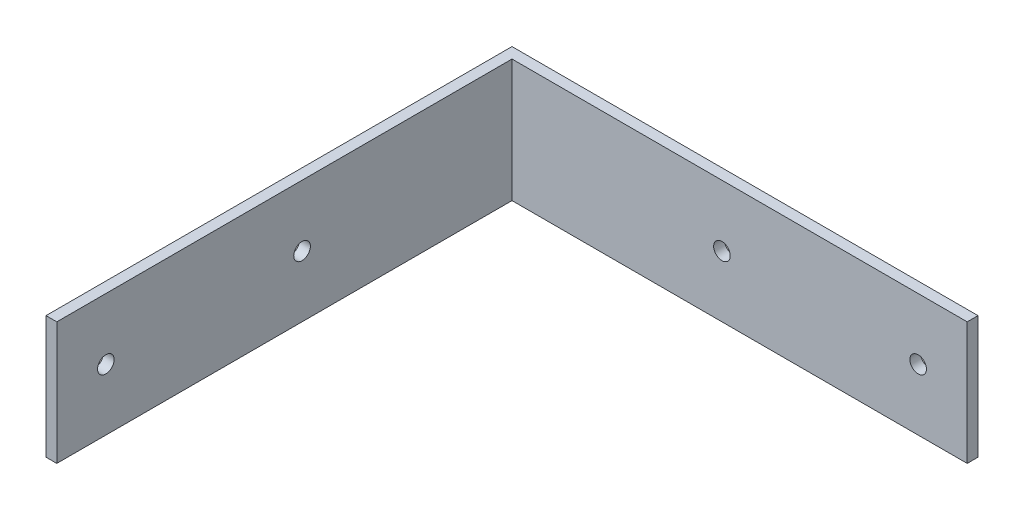
from build123d import *

# Parameters (mm, degrees)
BOSS_EXTRUDE1_DEPTH       = 31.75
F_8_CLEARANCE_HOLE1_D     = 4.3053
F_8_CLEARANCE_HOLE1_DEPTH = 6.35
F_8_CLEARANCE_HOLE1_TIP   = 1.293442612
F_8_CLEARANCE_HOLE2_D     = 4.3053
F_8_CLEARANCE_HOLE2_DEPTH = 6.35
F_8_CLEARANCE_HOLE2_TIP   = 1.293442612


with BuildPart() as part:
    # Sketch1 → Boss-Extrude1 (new body)
    with BuildSketch(Plane(origin=(0, 0, 0), x_dir=(1, 0, 0), z_dir=(0, 1, 0))):
        Polygon((0, 0), (120.65, 0), (120.65, -2.794), (2.794, -2.794), (2.794, -120.65), (0, -120.65), align=None)
    extrude(amount=BOSS_EXTRUDE1_DEPTH)

    # #8 Clearance Hole1
    with Locations(Plane(origin=(0, 0, 0), x_dir=(-1, 0, 0), z_dir=(0, 0, -1))):
        with Locations((-107.95, 15.875), (-57.15, 15.875)):
            Hole(F_8_CLEARANCE_HOLE1_D / 2, depth=F_8_CLEARANCE_HOLE1_DEPTH)
            with Locations((0, 0, -(F_8_CLEARANCE_HOLE1_DEPTH + F_8_CLEARANCE_HOLE1_TIP / 2))):  # 118° drill point
                Cone(0, F_8_CLEARANCE_HOLE1_D / 2, F_8_CLEARANCE_HOLE1_TIP, mode=Mode.SUBTRACT)

    # #8 Clearance Hole2
    with Locations(Plane.ZY):
        with Locations((107.95, 15.875), (57.15, 15.875)):
            Hole(F_8_CLEARANCE_HOLE2_D / 2, depth=F_8_CLEARANCE_HOLE2_DEPTH)
            with Locations((0, 0, -(F_8_CLEARANCE_HOLE2_DEPTH + F_8_CLEARANCE_HOLE2_TIP / 2))):  # 118° drill point
                Cone(0, F_8_CLEARANCE_HOLE2_D / 2, F_8_CLEARANCE_HOLE2_TIP, mode=Mode.SUBTRACT)


solid = part.part
